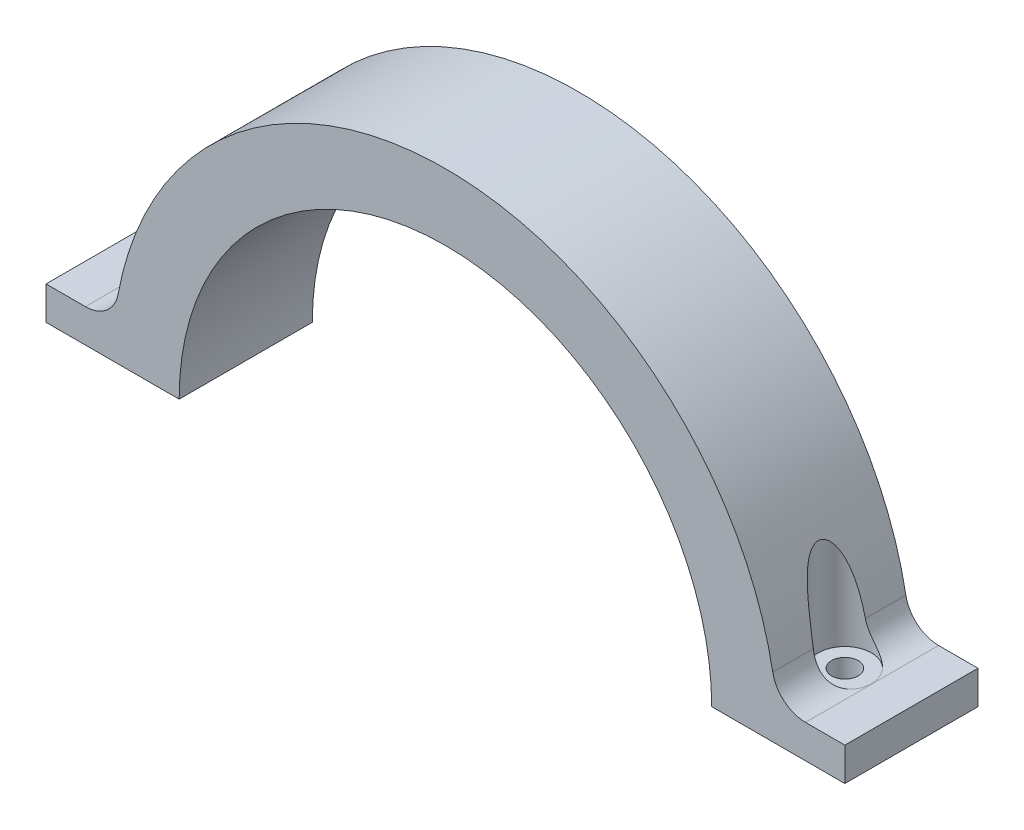
from build123d import *

# Parameters (mm, degrees)
BOSS_EXTRUDE1_DEPTH = 20
CUT_EXTRUDE1_DEPTH  = 20
SKETCH4_R           = 4
SKETCH4_R_2         = 2
CUT_EXTRUDE2_DEPTH  = 37


with BuildPart() as part:
    # Sketch1 → Boss-Extrude1 (new body)
    with BuildSketch(Plane.XY):
        with BuildLine():
            Line((-40, 0), (-60, 0))
            Line((-60, 0), (-60, 5))
            Line((-60, 5), (-54.083269132, 5))
            ThreePointArc((-54.083269132, 5), (-50.885258387, 6.156469426), (-49.166608302, 9.090909091))
            ThreePointArc((-49.166608302, 9.090909091), (-31.980107453, 38.435305739), (0, 50))
            Line((0, 50), (0, 40))
            ThreePointArc((0, 40), (-28.284271247, 28.284271247), (-40, 0))
        make_face()
    boss_extrude1 = extrude(amount=BOSS_EXTRUDE1_DEPTH)

    # Sketch2 → Cut-Extrude1 (cut)
    with BuildSketch(Plane.XZ):
        with BuildLine():
            ThreePointArc((-48, 10), (-49.234633135, 11.847759065), (-51.414213562, 11.414213562))
            Line((-51.414213562, 11.414213562), (-48.585786438, 8.585786438))
            ThreePointArc((-48.585786438, 8.585786438), (-48.152240935, 9.234633135), (-48, 10))
        make_face()
        with BuildLine():
            Line((-48.585786438, 8.585786438), (-51.414213562, 11.414213562))
            ThreePointArc((-51.414213562, 11.414213562), (-51.414213562, 8.585786438), (-48.585786438, 8.585786438))
        make_face()
    cut_extrude1 = extrude(amount=-CUT_EXTRUDE1_DEPTH, mode=Mode.SUBTRACT)

    # Sketch4 → Cut-Extrude2 (cut)
    with BuildSketch(Plane(origin=(0, 5, 0), x_dir=(1, 0, 0), z_dir=(0, 1, 0))):
        with Locations((-50, -10)):
            Circle(SKETCH4_R)
        with Locations((-50, -10)):
            Circle(SKETCH4_R_2, mode=Mode.SUBTRACT)
    cut_extrude2 = extrude(amount=CUT_EXTRUDE2_DEPTH, mode=Mode.SUBTRACT)

    # Mirror1: Boss-Extrude1, Cut-Extrude1, Cut-Extrude2 across plane
    add(boss_extrude1.mirror(Plane(origin=(0, 0, 20), x_dir=(0, 0, 1), z_dir=(1, 0, 0))))
    add(cut_extrude1.mirror(Plane(origin=(0, 0, 20), x_dir=(0, 0, 1), z_dir=(1, 0, 0))), mode=Mode.SUBTRACT)
    add(cut_extrude2.mirror(Plane(origin=(0, 0, 20), x_dir=(0, 0, 1), z_dir=(1, 0, 0))), mode=Mode.SUBTRACT)


solid = part.part
